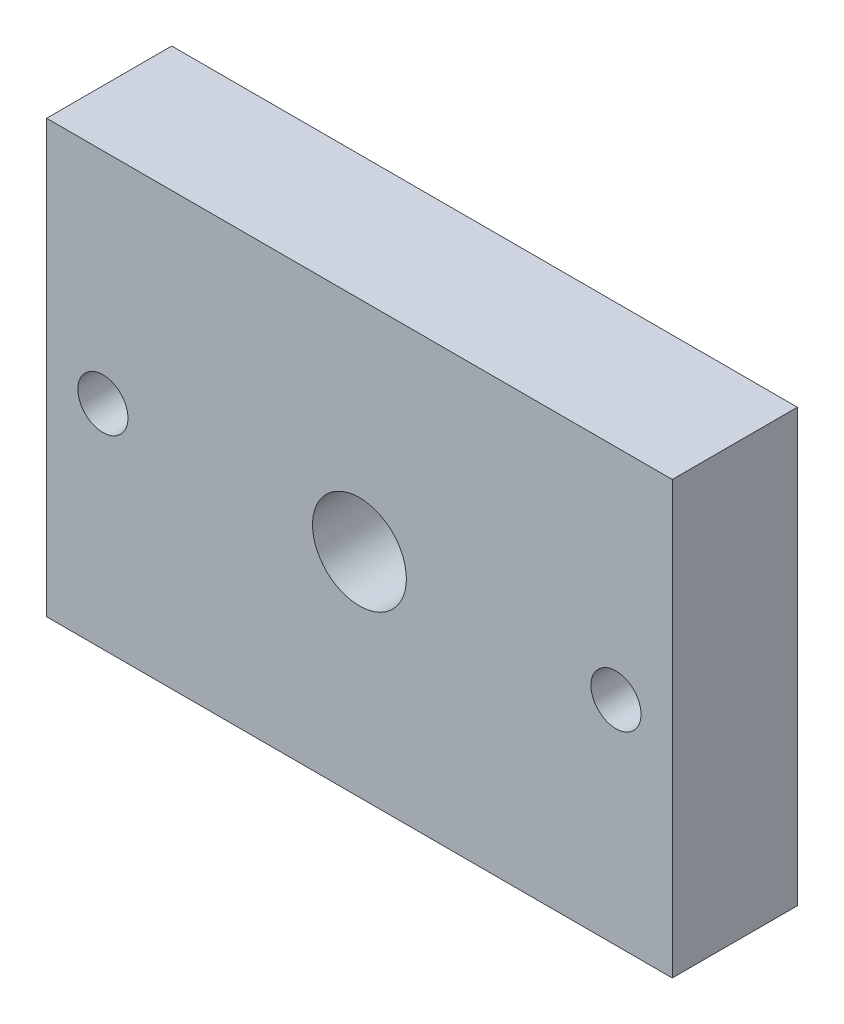
from build123d import *

# Parameters (mm, degrees)
SKETCH1_W               = 100
SKETCH1_H               = 70
BOSS_EXTRUDE1_DEPTH     = 20
SKETCH2_R               = 4
CUT_EXTRUDE1_DEPTH      = 21
CUT_EXTRUDE1_DEPTH_BACK = 1
SKETCH3_R               = 7.5
CUT_EXTRUDE2_DEPTH      = 15
SKETCH4_W               = 100
SKETCH4_H               = 1
CUT_EXTRUDE3_DEPTH      = 21
CUT_EXTRUDE3_DEPTH_BACK = 1


with BuildPart() as part:
    # Sketch1 → Boss-Extrude1 (new body)
    with BuildSketch(Plane.XY):
        Rectangle(SKETCH1_W, SKETCH1_H)
    extrude(amount=BOSS_EXTRUDE1_DEPTH)

    # Sketch2 → Cut-Extrude1 (cut, two sides)
    with BuildSketch(Plane.XY) as cut_extrude1_sk:
        with Locations((-41, 0)):
            Circle(SKETCH2_R)
        with Locations((41, 0)):
            Circle(SKETCH2_R)
    extrude(amount=CUT_EXTRUDE1_DEPTH, mode=Mode.SUBTRACT)
    extrude(cut_extrude1_sk.sketch, amount=-CUT_EXTRUDE1_DEPTH_BACK, mode=Mode.SUBTRACT)

    # Sketch3 → Cut-Extrude2 (cut)
    with BuildSketch(Plane.XY.offset(20)):
        Circle(SKETCH3_R)
    extrude(amount=-CUT_EXTRUDE2_DEPTH, mode=Mode.SUBTRACT)

    # Sketch4 → Cut-Extrude3 (cut, two sides)
    with BuildSketch(Plane.XY) as cut_extrude3_sk:
        with Locations((0, -34.5)):
            Rectangle(SKETCH4_W, SKETCH4_H)
    extrude(amount=CUT_EXTRUDE3_DEPTH, mode=Mode.SUBTRACT)
    extrude(cut_extrude3_sk.sketch, amount=-CUT_EXTRUDE3_DEPTH_BACK, mode=Mode.SUBTRACT)


solid = part.part
